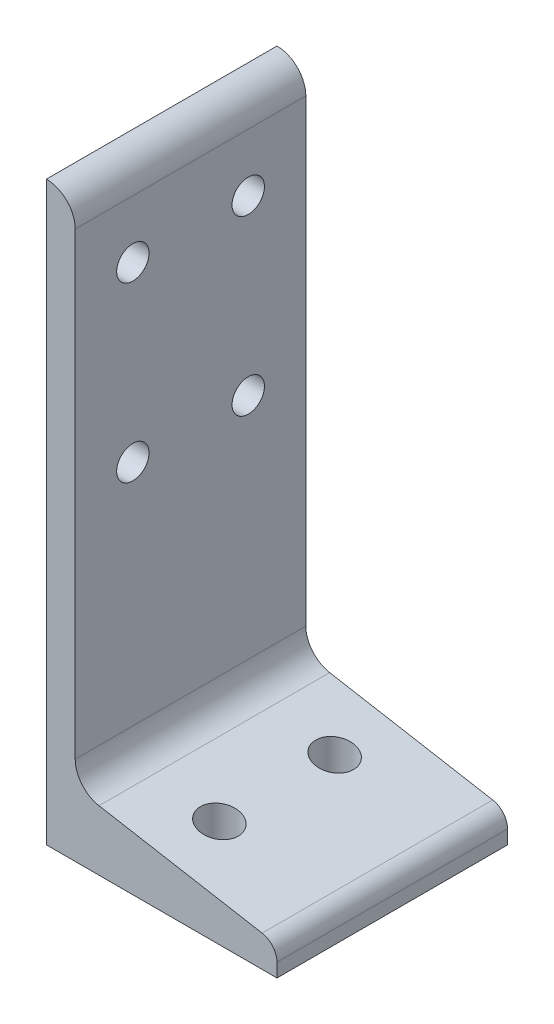
from build123d import *

# Parameters (mm, degrees)
EXTRUDE1_DEPTH     = 50.8
SKETCH2_R          = 3.5687
CUT_EXTRUDE1_DEPTH = 7.3500001
SKETCH3_R          = 4.1656
CUT_EXTRUDE2_DEPTH = 128.0000001


with BuildPart() as part:
    # Sketch1 → Extrude1 (new body)
    with BuildSketch(Plane.XY):
        with BuildLine():
            Line((24.787766027, 20.626332144), (6.630852488, 23.827885887))
            Line((6.630852488, 23.827885887), (-1.306647512, 25.227481296))
            Line((-1.306647512, 25.227481296), (-11.14056344, 26.961466))
            add(Edge.make_bspline(
                [(-16.387897512, 33.214995232), (-16.387897512, 27.886712574), (-11.14056344, 26.961466)],
                knots=[1.570796327, 1.570796327, 1.570796327, 2.967059728, 2.967059728, 2.967059728], degree=2, weights=[1, 0.766044443, 1]))
            Line((-16.387897512, 33.214995232), (-16.387897512, 79.980278282))
            Line((-16.387897512, 79.980278282), (-16.387897512, 87.117678282))
            Line((-16.387897512, 87.117678282), (-16.387897512, 118.080278282))
            Line((-16.387897512, 118.080278282), (-16.387897512, 125.217678282))
            Line((-16.387897512, 125.217678282), (-16.387897512, 134.348978282))
            add(Edge.make_bspline(
                [(-16.387897512, 134.348978282), (-16.387897512, 140.698978282), (-22.737897512, 140.698978282)],
                knots=[3.141592654, 3.141592654, 3.141592654, 4.71238898, 4.71238898, 4.71238898], degree=2, weights=[1, 0.707106781, 1]))
            Line((-22.737897512, 140.698978282), (-22.737897512, 125.217678282))
            Line((-22.737897512, 125.217678282), (-22.737897512, 118.080278282))
            Line((-22.737897512, 118.080278282), (-22.737897512, 87.117678282))
            Line((-22.737897512, 87.117678282), (-22.737897512, 79.980278282))
            Line((-22.737897512, 79.980278282), (-22.737897512, 13.698978282))
            Line((-22.737897512, 13.698978282), (-1.306647512, 13.698978282))
            Line((-1.306647512, 13.698978282), (6.630852488, 13.698978282))
            Line((6.630852488, 13.698978282), (28.062102488, 13.698978282))
            Line((28.062102488, 13.698978282), (28.062102488, 16.724129903))
            add(Edge.make_bspline(
                [(28.062102488, 16.724129903), (28.062102488, 20.048978282), (24.787766027, 20.626332144)],
                knots=[0, 0, 0, 1.396263402, 1.396263402, 1.396263402], degree=2, weights=[1, 0.766044443, 1]))
        make_face()
    extrude(amount=EXTRUDE1_DEPTH)

    # Sketch2 → Cut-Extrude1 (cut, through all)
    with BuildSketch(Plane(origin=(-16.387897512, 0, 0), x_dir=(0, 0, -1), z_dir=(1, 0, 0))):
        with Locations((-38.1, 121.648978282)):
            Circle(SKETCH2_R)
        with Locations((-38.1, 83.548978282)):
            Circle(SKETCH2_R)
        with Locations((-12.685238078, 83.548978282)):
            Circle(SKETCH2_R)
        with Locations((-12.685238078, 121.64899544)):
            Circle(SKETCH2_R)
    extrude(amount=-CUT_EXTRUDE1_DEPTH, mode=Mode.SUBTRACT)

    # Sketch3 → Cut-Extrude2 (cut, through all)
    with BuildSketch(Plane.XZ.offset(-13.698978282)):
        with Locations((2.662102488, 12.7)):
            Circle(SKETCH3_R)
        with Locations((2.662102488, 38.1)):
            Circle(SKETCH3_R)
    extrude(amount=-CUT_EXTRUDE2_DEPTH, mode=Mode.SUBTRACT)


solid = part.part
